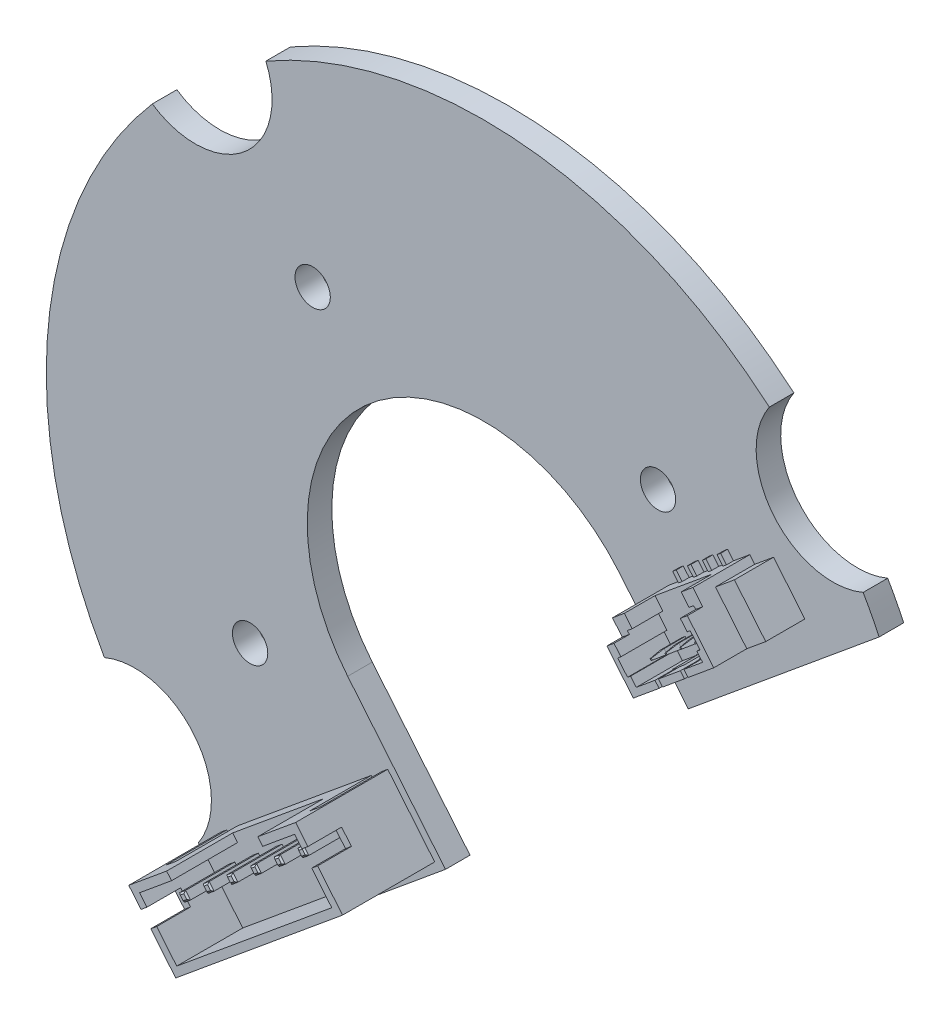
from build123d import *

# Parameters (mm, degrees)
EXTRUDE_1_DEPTH        = 1.6
EXTRUDE_2_DEPTH        = 6
CUT_EXTRUDE_1_DEPTH    = 4.3
CUT_EXTRUDE_2_DEPTH    = 2.2
SKETCH_6_W             = 0.9
SKETCH_6_H             = 4
CUT_EXTRUDE_3_DEPTH    = 0.5
EXTRUDE_3_DEPTH        = 3.3
EXTRUDE_4_DEPTH        = 4.4
CHAMFER_1_SIZE         = 0.1
CHAMFER_2_SIZE         = 0.1
EXTRUDE_5_DEPTH        = 1
SKETCH_9_R             = 2.5
EXTRUDE_6_DEPTH        = 7.5
FILLET_2_R             = 2.5
SKETCH_10_R            = 1.15
CUT_EXTRUDE_4_DEPTH    = 2.4
EXTRUDE_7_DEPTH        = 4.7
CUT_EXTRUDE_5_DEPTH    = 2.15
CUT_EXTRUDE_6_DEPTH    = 2.55
CUT_EXTRUDE_7_DEPTH    = 3
CUT_EXTRUDE_8_DEPTH    = 1
CUT_EXTRUDE_9_DEPTH    = 0.45
EXTRUDE_8_DEPTH        = 2.2
CHAMFER_3_SIZE         = 0.1
CHAMFER_3_SIZE2        = 0.814434643
CHAMFER_3_PART_2_SIZE  = 0.1
CHAMFER_3_PART_2_SIZE2 = 0.814434643
CHAMFER_3_PART_3_SIZE  = 0.1
CHAMFER_3_PART_3_SIZE2 = 0.814434643
CHAMFER_3_PART_4_SIZE  = 0.1
CHAMFER_3_PART_4_SIZE2 = 0.814434643
EXTRUDE_9_DEPTH        = 0.46


with BuildPart() as part:
    # 草图2 → 凸台-拉伸1 (new body)
    with BuildSketch(Plane.XY):
        with BuildLine():
            Line((-14.203628819, -24.708438404), (-2.495424261, -15.034056597))
            Line((-2.495424261, -15.034056597), (-8.865172733, -7.325210742))
            ThreePointArc((-8.865172733, -7.325210742), (-7.325210742, 8.865172733), (8.865172733, 7.325210742))
            Line((8.865172733, 7.325210742), (13.323996663, 1.929018644))
            Line((13.323996663, 1.929018644), (25.756036621, 12.201498989))
            ThreePointArc((25.756036621, 12.201498989), (25.254138614, 13.209030353), (24.712846916, 14.195957076))
            ThreePointArc((24.712846916, 14.195957076), (18.886672343, 15.605883756), (18.600414114, 21.593392387))
            ThreePointArc((18.600414114, 21.593392387), (2.698621794, 28.371948125), (-14.195957076, 24.712846916))
            ThreePointArc((-14.195957076, 24.712846916), (-15.605883756, 18.886672343), (-21.593392387, 18.600414114))
            ThreePointArc((-21.593392387, 18.600414114), (-28.371948125, 2.698621794), (-24.712846916, -14.195957076))
            ThreePointArc((-24.712846916, -14.195957076), (-18.886672343, -15.605883756), (-18.600414114, -21.593392387))
            ThreePointArc((-18.600414114, -21.593392387), (-16.475806084, -23.255059963), (-14.203628819, -24.708438404))
        make_face()
    extrude(amount=EXTRUDE_1_DEPTH)

    # 草图3 → 凸台-拉伸2 (add)
    with BuildSketch(Plane.XY.offset(1.6)):
        Polygon((-6.256833244, -11.266855718), (-3.199353977, -14.967101728), (-14.068826632, -23.948447073), (-17.126305898, -20.248201063), align=None)
    extrude(amount=EXTRUDE_2_DEPTH)

    # 草图4 → 切除-拉伸1 (cut)
    with BuildSketch(Plane.XY.offset(7.6)):
        Polygon((-6.323788113, -11.970785434), (-3.903283694, -14.900146859), (-14.001871763, -23.244517357), (-16.422376182, -20.315155932), (-14.340987801, -18.595323844), (-14.659475225, -18.209881552), (-8.721351263, -13.303264304), (-8.40286384, -13.688706597), align=None)
    extrude(amount=-CUT_EXTRUDE_1_DEPTH, mode=Mode.SUBTRACT)

    # 草图5 → 切除-拉伸2 (cut)
    with BuildSketch(Plane.XY.offset(7.6)):
        Polygon((-5.846056977, -12.548948873), (-5.460614685, -12.230461449), (-4.823639838, -13.001346035), (-5.20908213, -13.319833458), align=None)
        Polygon((-15.944645047, -20.893319371), (-16.330087339, -21.211806794), (-15.693112492, -21.98269138), (-15.3076702, -21.664203956), align=None)
    extrude(amount=-CUT_EXTRUDE_2_DEPTH, mode=Mode.SUBTRACT)

    # 草图6 → 切除-拉伸3 (cut)
    with BuildSketch(Plane(origin=(2.993781782, -3.623157552, 0), x_dir=(0.770884585, 0.636974847, 0), z_dir=(-0.636974847, 0.770884585, 0))):
        with Locations((-12.95, -3.6)):
            Rectangle(SKETCH_6_W, SKETCH_6_H)
        with Locations((-25.15, -3.6)):
            Rectangle(SKETCH_6_W, SKETCH_6_H)
    extrude(amount=-CUT_EXTRUDE_3_DEPTH, mode=Mode.SUBTRACT)

    # 草图7 → 凸台-拉伸3 (add)
    with BuildSketch(Plane.XY.offset(3.3)):
        Polygon((-6.816358196, -13.415560404), (-6.497870773, -13.801002696), (-6.883313065, -14.11949012), (-7.201800489, -13.734047827), align=None)
        Polygon((-8.425082236, -15.393439814), (-8.74356966, -15.007997522), (-8.358127367, -14.689510098), (-8.039639943, -15.074952391), align=None)
        Polygon((-9.966851407, -16.667389509), (-10.285338831, -16.281947216), (-9.899896538, -15.963459792), (-9.581409114, -16.348902085), align=None)
        Polygon((-11.508620578, -17.941339203), (-11.827108001, -17.55589691), (-11.441665709, -17.237409487), (-11.123178285, -17.622851779), align=None)
        Polygon((-13.050389749, -19.215288897), (-13.368877172, -18.829846605), (-12.98343488, -18.511359181), (-12.664947456, -18.896801474), align=None)
        Polygon((-14.59215892, -20.489238592), (-14.910646343, -20.103796299), (-14.525204051, -19.785308875), (-14.206716627, -20.170751168), align=None)
    extrude(amount=EXTRUDE_3_DEPTH)

    # 草图7<3> → 凸台-拉伸4 (add)
    with BuildSketch(Plane.XY.offset(3.3)):
        Polygon((-6.816358196, -13.415560404), (-6.497870773, -13.801002696), (-6.883313065, -14.11949012), (-7.201800489, -13.734047827), align=None)
        Polygon((-8.425082236, -15.393439814), (-8.74356966, -15.007997522), (-8.358127367, -14.689510098), (-8.039639943, -15.074952391), align=None)
        Polygon((-9.966851407, -16.667389509), (-10.285338831, -16.281947216), (-9.899896538, -15.963459792), (-9.581409114, -16.348902085), align=None)
        Polygon((-11.508620578, -17.941339203), (-11.827108001, -17.55589691), (-11.441665709, -17.237409487), (-11.123178285, -17.622851779), align=None)
        Polygon((-13.050389749, -19.215288897), (-13.368877172, -18.829846605), (-12.98343488, -18.511359181), (-12.664947456, -18.896801474), align=None)
        Polygon((-14.59215892, -20.489238592), (-14.910646343, -20.103796299), (-14.525204051, -19.785308875), (-14.206716627, -20.170751168), align=None)
    extrude(amount=-EXTRUDE_4_DEPTH)

    # 倒角1
    chamfer_1_edges = [part.edges().sort_by_distance(p)[0] for p in [
        (-7.009079342, -13.574804115, 6.6),
        (-7.042556777, -13.926768974, 6.6),
        (-6.690591919, -13.960246408, 6.6),
        (-6.657114484, -13.60828155, 6.6),
        (-8.198883655, -14.882231244, 6.6),
        (-8.550848513, -14.84875381, 6.6),
        (-8.584325948, -15.200718668, 6.6),
        (-8.23236109, -15.234196102, 6.6),
        (-9.740652826, -16.156180939, 6.6),
        (-10.092617684, -16.122703504, 6.6),
        (-10.126095119, -16.474668362, 6.6),
        (-9.774130261, -16.508145797, 6.6),
        (-11.282421997, -17.430130633, 6.6),
        (-11.634386855, -17.396653198, 6.6),
        (-11.66786429, -17.748618057, 6.6),
        (-11.315899432, -17.782095491, 6.6),
        (-12.824191168, -18.704080327, 6.6),
        (-13.176156026, -18.670602893, 6.6),
        (-13.209633461, -19.022567751, 6.6),
        (-12.857668602, -19.056045185, 6.6),
        (-14.365960339, -19.978030022, 6.6),
        (-14.717925197, -19.944552587, 6.6),
        (-14.751402631, -20.296517445, 6.6),
        (-14.399437773, -20.32999488, 6.6),
    ]]
    chamfer(chamfer_1_edges, length=CHAMFER_1_SIZE)

    # 倒角2
    chamfer_2_edges = [part.edges().sort_by_distance(p)[0] for p in [
        (-7.009079342, -13.574804115, -1.1),
        (-6.657114484, -13.60828155, -1.1),
        (-6.690591919, -13.960246408, -1.1),
        (-7.042556777, -13.926768974, -1.1),
        (-8.198883655, -14.882231244, -1.1),
        (-8.23236109, -15.234196102, -1.1),
        (-8.584325948, -15.200718668, -1.1),
        (-8.550848513, -14.84875381, -1.1),
        (-9.740652826, -16.156180939, -1.1),
        (-9.774130261, -16.508145797, -1.1),
        (-10.126095119, -16.474668362, -1.1),
        (-10.092617684, -16.122703504, -1.1),
        (-11.282421997, -17.430130633, -1.1),
        (-11.315899432, -17.782095491, -1.1),
        (-11.66786429, -17.748618057, -1.1),
        (-11.634386855, -17.396653198, -1.1),
        (-12.824191168, -18.704080327, -1.1),
        (-12.857668602, -19.056045185, -1.1),
        (-13.209633461, -19.022567751, -1.1),
        (-13.176156026, -18.670602893, -1.1),
        (-14.365960339, -19.978030022, -1.1),
        (-14.399437773, -20.32999488, -1.1),
        (-14.751402631, -20.296517445, -1.1),
        (-14.717925197, -19.944552587, -1.1),
    ]]
    chamfer(chamfer_2_edges, length=CHAMFER_2_SIZE)

    # 草图8 → 凸台-拉伸5 (add)
    with BuildSketch(Plane(origin=(0, 0, 0), x_dir=(-1, 0, 0), z_dir=(0, 0, -1))):
        with BuildLine():
            Line((27.818549453, 4.149402696), (28.101982946, 1.169525944))
            ThreePointArc((28.101982946, 1.169525944), (22.38542727, 2.12920881), (27.818549453, 4.149402696))
        make_face()
    extrude(amount=EXTRUDE_5_DEPTH)

    # 草图9 → 凸台-拉伸6 (add)
    with BuildSketch(Plane(origin=(0, 0, -1), x_dir=(-1, 0, 0), z_dir=(0, 0, -1))):
        with Locations((25.371948125, 2.413274262)):
            Circle(SKETCH_9_R)
    extrude(amount=EXTRUDE_6_DEPTH)

    # 圆角2
    fillet_2_edges = [part.edges().sort_by_distance(p)[0] for p in [
        (-22.871948125, 2.413274262, -8.5),
    ]]
    fillet(fillet_2_edges, radius=FILLET_2_R)

    # 草图10 → 切除-拉伸4 (cut)
    with BuildSketch(Plane.XY.offset(1.6)):
        with Locations((11.349862912, 13.32030825)):
            Circle(SKETCH_10_R)
        with Locations((-11.147059825, 13.490480245)):
            Circle(SKETCH_10_R)
        with Locations((-15.221196162, -8.635113629)):
            Circle(SKETCH_10_R)
    extrude(amount=-CUT_EXTRUDE_4_DEPTH, mode=Mode.SUBTRACT)

    # 草图11 → 凸台-拉伸7 (add)
    with BuildSketch(Plane.XY.offset(1.6)):
        Polygon((10.849566912, 7.278523052), (18.558412767, 13.648271524), (20.915219701, 10.795998558), (13.206373847, 4.426250086), align=None)
    extrude(amount=EXTRUDE_7_DEPTH)

    # 草图12 → 切除-拉伸5 (cut)
    with BuildSketch(Plane.XY.offset(6.3)):
        Polygon((17.32499743, 12.629111768), (19.681804364, 9.776838802), (20.915219701, 10.795998558), (18.558412767, 13.648271524), align=None)
        Polygon((10.849566912, 7.278523052), (12.082982249, 8.297682808), (14.439789183, 5.445409841), (13.206373847, 4.426250086), align=None)
    extrude(amount=-CUT_EXTRUDE_5_DEPTH, mode=Mode.SUBTRACT)

    # 草图13 → 切除-拉伸6 (cut)
    with BuildSketch(Plane.XY.offset(4.15)):
        Polygon((18.558412767, 13.648271524), (17.32499743, 12.629111768), (17.643484853, 12.243669476), (18.87690019, 13.262829231), align=None)
        Polygon((12.082982249, 8.297682808), (10.849566912, 7.278523052), (11.168054336, 6.893080759), (12.401469672, 7.912240515), align=None)
    extrude(amount=-CUT_EXTRUDE_6_DEPTH, mode=Mode.SUBTRACT)

    # 草图14 → 切除-拉伸7 (cut)
    with BuildSketch(Plane.XY.offset(6.3)):
        Polygon((16.554112844, 11.992136921), (17.063692722, 11.375429253), (17.372046556, 11.630219192), (17.945323919, 10.936423065), (18.145753911, 11.102036525), (18.782728758, 10.33115194), (18.582298766, 10.165538479), (18.951744177, 9.71842542), (14.634790499, 6.151366276), (14.265345087, 6.598479335), (14.064915095, 6.432865875), (13.427940248, 7.20375046), (13.62837024, 7.369363921), (13.055092878, 8.063160048), (13.363446712, 8.317949986), (12.853866834, 8.934657655), align=None)
    extrude(amount=-CUT_EXTRUDE_7_DEPTH, mode=Mode.SUBTRACT)

    # 草图15 → 切除-拉伸8 (cut)
    with BuildSketch(Plane.XY.offset(6.3)):
        Polygon((12.082982249, 8.297682808), (17.32499743, 12.629111768), (17.961972277, 11.858227183), (12.719957096, 7.526798222), align=None)
    extrude(amount=-CUT_EXTRUDE_8_DEPTH, mode=Mode.SUBTRACT)

    # 草图16 → 切除-拉伸9 (cut)
    with BuildSketch(Plane(origin=(3.184874236, -3.854422927, 0), x_dir=(0.770884585, 0.636974847, 0), z_dir=(0.636974847, -0.770884585, 0))):
        Polygon((16.43, 4.9), (16.78, 4.9), (16.78, 6.3), (17.08, 6.3), (17.08, 4.9), (17.43, 4.9), (17.43, 1.6), (16.43, 1.6), align=None)
        Polygon((18.57, 4.9), (18.92, 4.9), (18.92, 6.3), (19.22, 6.3), (19.22, 4.9), (19.57, 4.9), (19.57, 1.6), (18.57, 1.6), align=None)
    extrude(amount=-CUT_EXTRUDE_9_DEPTH, mode=Mode.SUBTRACT)

    # 草图17 → 凸台-拉伸8 (add)
    with BuildSketch(Plane.XY.offset(3.3)):
        Polygon((17.714818451, 10.006548219), (17.905910905, 9.775282843), (17.674645529, 9.584190389), (17.483553075, 9.815455765), align=None)
        Polygon((16.711039798, 8.78797183), (16.519947343, 9.019237206), (16.751212719, 9.21032966), (16.942305173, 8.979064284), align=None)
        Polygon((15.747434066, 7.991753271), (15.556341612, 8.223018647), (15.787606987, 8.414111101), (15.978699441, 8.182845725), align=None)
        Polygon((14.783828334, 7.195534712), (14.59273588, 7.426800088), (14.824001255, 7.617892542), (15.01509371, 7.386627166), align=None)
    extrude(amount=EXTRUDE_8_DEPTH)

    # 倒角3
    chamfer_3_edges = [part.edges().sort_by_distance(p)[0] for p in [
        (17.810364678, 9.890915531, 5.5),
        (17.790278217, 9.679736616, 5.5),
        (17.579099302, 9.699823077, 5.5),
        (17.599185763, 9.911001992, 5.5),
    ]]
    chamfer_3_side = [part.faces().sort_by_distance(p)[0] for p in [
        (17.69473199, 9.795369304, 5.5),
    ]]
    chamfer(chamfer_3_edges, length=CHAMFER_3_SIZE, length2=CHAMFER_3_SIZE2, reference=chamfer_3_side[0])

    # 倒角3 part 2
    chamfer_3_part_2_edges = [part.edges().sort_by_distance(p)[0] for p in [
        (16.826672485, 8.883518057, 5.5),
        (16.61549357, 8.903604518, 5.5),
        (16.635580031, 9.114783433, 5.5),
        (16.846758946, 9.094696972, 5.5),
    ]]
    chamfer_3_part_2_side = [part.faces().sort_by_distance(p)[0] for p in [
        (16.731126258, 8.999150745, 5.5),
    ]]
    chamfer(chamfer_3_part_2_edges, length=CHAMFER_3_PART_2_SIZE, length2=CHAMFER_3_PART_2_SIZE2, reference=chamfer_3_part_2_side[0])

    # 倒角3 part 3
    chamfer_3_part_3_edges = [part.edges().sort_by_distance(p)[0] for p in [
        (15.863066754, 8.087299498, 5.5),
        (15.651887839, 8.107385959, 5.5),
        (15.671974299, 8.318564874, 5.5),
        (15.883153214, 8.298478413, 5.5),
    ]]
    chamfer_3_part_3_side = [part.faces().sort_by_distance(p)[0] for p in [
        (15.767520526, 8.202932186, 5.5),
    ]]
    chamfer(chamfer_3_part_3_edges, length=CHAMFER_3_PART_3_SIZE, length2=CHAMFER_3_PART_3_SIZE2, reference=chamfer_3_part_3_side[0])

    # 倒角3 part 4
    chamfer_3_part_4_edges = [part.edges().sort_by_distance(p)[0] for p in [
        (14.899461022, 7.291080939, 5.5),
        (14.688282107, 7.3111674, 5.5),
        (14.708368568, 7.522346315, 5.5),
        (14.919547482, 7.502259854, 5.5),
    ]]
    chamfer_3_part_4_side = [part.faces().sort_by_distance(p)[0] for p in [
        (14.803914795, 7.406713627, 5.5),
    ]]
    chamfer(chamfer_3_part_4_edges, length=CHAMFER_3_PART_4_SIZE, length2=CHAMFER_3_PART_4_SIZE2, reference=chamfer_3_part_4_side[0])

    # 草图18 → 凸台-拉伸9 (add)
    with BuildSketch(Plane.XY.offset(1.6)):
        Polygon((13.146802977, 9.176708097), (12.764618068, 9.639238848), (12.995883444, 9.830331302), (13.378068352, 9.367800551), align=None)
        Polygon((13.7282238, 10.435457407), (13.959489176, 10.626549861), (14.341674084, 10.16401911), (14.110408709, 9.972926656), align=None)
        Polygon((14.691829532, 11.231675966), (14.923094908, 11.42276842), (15.305279816, 10.960237669), (15.07401444, 10.769145215), align=None)
        Polygon((15.655435264, 12.027894525), (15.886700639, 12.218986979), (16.268885548, 11.756456228), (16.037620172, 11.565363774), align=None)
    extrude(amount=EXTRUDE_9_DEPTH)


solid = part.part
